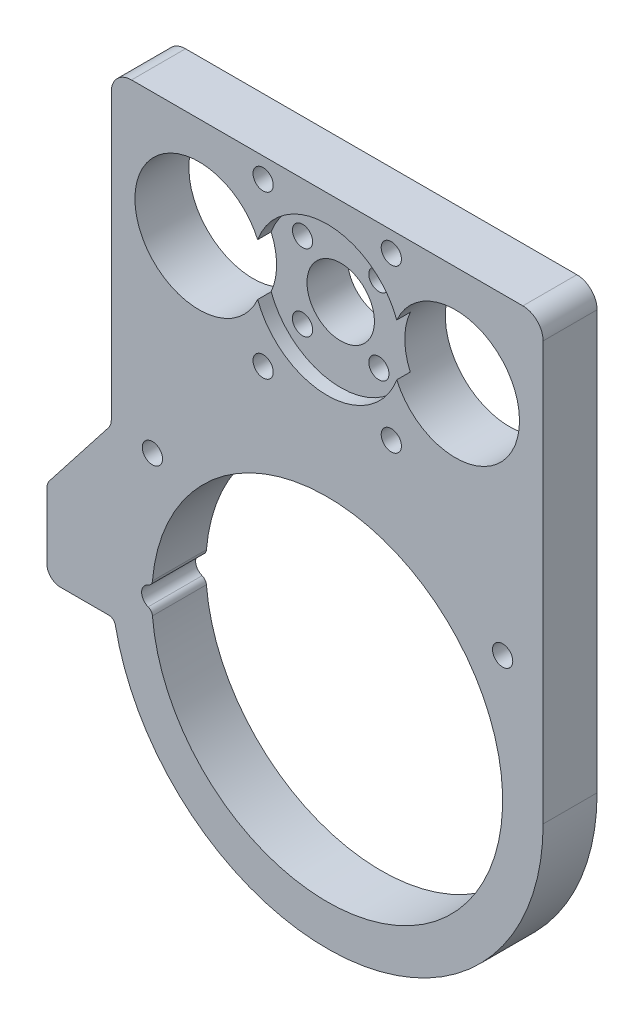
from build123d import *

# Parameters (mm, degrees)
SKETCH_1_R          = 5
SKETCH_1_R_2        = 9.5
SKETCH_1_R_3        = 1.5
EXTRUDE_1_DEPTH     = 8
SKETCH_2_R          = 11
CUT_EXTRUDE_1_DEPTH = 2


with BuildPart() as part:
    # Эскиз1 → Бобышка-Вытянуть1 (new body)
    with BuildSketch(Plane.XY):
        with BuildLine():
            Line((32, -50), (32, -17))
            Line((32, -17), (32, 12))
            ThreePointArc((32, 12), (31.121320344, 14.121320344), (29, 15))
            Line((29, 15), (-29, 15))
            ThreePointArc((-29, 15), (-31.121320344, 14.121320344), (-32, 12))
            Line((-32, 12), (-32, -17))
            Line((-32, -17), (-32, -30.127300246))
            ThreePointArc((-32, -30.127300246), (-32.109032978, -30.77864019), (-32.424243723, -31.358962601))
            Line((-32.424243723, -31.358962601), (-41.119742613, -42.483754153))
            ThreePointArc((-41.119742613, -42.483754153), (-41.434953358, -43.064076563), (-41.543986336, -43.715416508))
            Line((-41.543986336, -43.715416508), (-41.543986336, -52.683803611))
            Line((-41.543986336, -52.683803611), (-41.543986336, -53.383022016))
            ThreePointArc((-41.543986336, -53.383022016), (-40.958199899, -54.797235578), (-39.543986336, -55.383022016))
            Line((-39.543986336, -55.383022016), (-32.37679771, -55.383022016))
            ThreePointArc((-32.37679771, -55.383022016), (-31.741748464, -55.610550363), (-31.395682628, -56.189597106))
            ThreePointArc((-31.395682628, -56.189597106), (3.109514103, -81.848562323), (32, -50))
        make_face()
        Circle(SKETCH_1_R, mode=Mode.SUBTRACT)
        with Locations((-19, 0)):
            Circle(SKETCH_1_R_2, mode=Mode.SUBTRACT)
        with Locations((19, 0)):
            Circle(SKETCH_1_R_2, mode=Mode.SUBTRACT)
        with Locations((-5.656854249, 5.656854249)):
            Circle(SKETCH_1_R_3, mode=Mode.SUBTRACT)
        with Locations((5.656854249, 5.656854249)):
            Circle(SKETCH_1_R_3, mode=Mode.SUBTRACT)
        with Locations((5.656854249, -5.656854249)):
            Circle(SKETCH_1_R_3, mode=Mode.SUBTRACT)
        with Locations((-5.656854249, -5.656854249)):
            Circle(SKETCH_1_R_3, mode=Mode.SUBTRACT)
        with Locations((-9.5, 12)):
            Circle(SKETCH_1_R_3, mode=Mode.SUBTRACT)
        with Locations((9.5, 12)):
            Circle(SKETCH_1_R_3, mode=Mode.SUBTRACT)
        with Locations((9.5, -12)):
            Circle(SKETCH_1_R_3, mode=Mode.SUBTRACT)
        with Locations((-9.5, -12)):
            Circle(SKETCH_1_R_3, mode=Mode.SUBTRACT)
        with Locations((-25.902777778, -31.358962601)):
            Circle(SKETCH_1_R_3, mode=Mode.SUBTRACT)
        with Locations((26, -31.358962601)):
            Circle(SKETCH_1_R_3, mode=Mode.SUBTRACT)
        with BuildLine():
            ThreePointArc((-25.902777778, -52.246353355), (26, -50), (-25.902777778, -47.753646645))
            ThreePointArc((-25.902777778, -47.753646645), (-26.099772408, -48.268225789), (-26.539423077, -48.600349063))
            ThreePointArc((-26.539423077, -48.600349063), (-27.5, -50), (-26.539423077, -51.399650937))
            ThreePointArc((-26.539423077, -51.399650937), (-26.099772408, -51.731774211), (-25.902777778, -52.246353355))
        make_face(mode=Mode.SUBTRACT)
    extrude(amount=EXTRUDE_1_DEPTH)

    # Эскиз2 → Вырез-Вытянуть1 (cut)
    with BuildSketch(Plane.XY.offset(8)):
        Circle(SKETCH_2_R)
    extrude(amount=-CUT_EXTRUDE_1_DEPTH, mode=Mode.SUBTRACT)


solid = part.part
